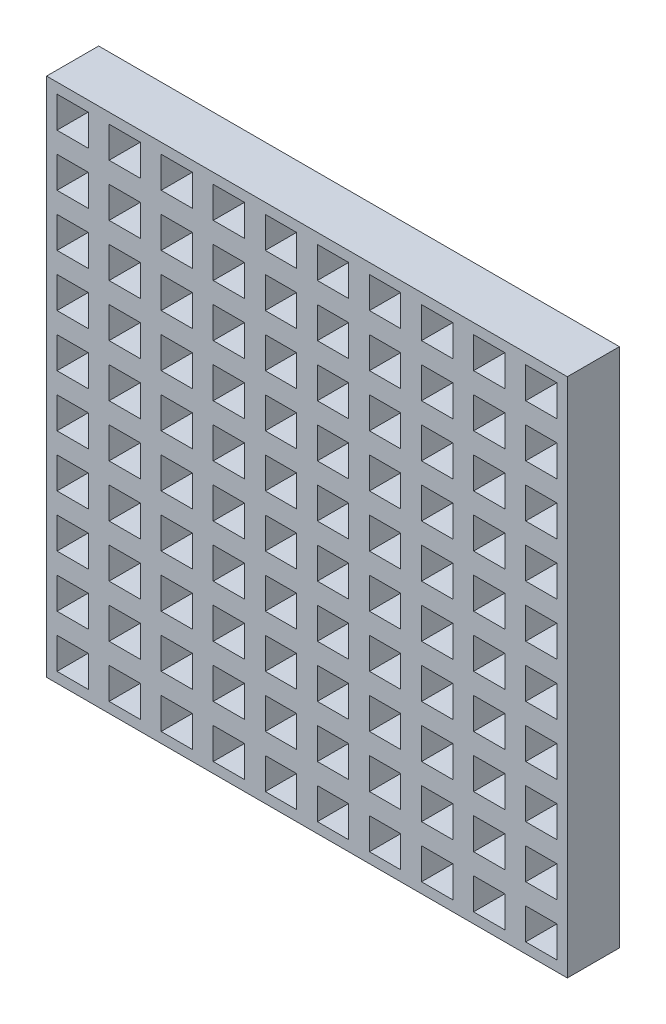
from build123d import *

# Parameters (mm, degrees)
SKETCH1_W           = 25.4
SKETCH1_H           = 25.4
BOSS_EXTRUDE1_DEPTH = 2.54
SKETCH2_W           = 1.524
SKETCH2_H           = 1.524
CUT_EXTRUDE1_DEPTH  = 2.54
LPATTERN1_COUNT     = 9
LPATTERN1_PITCH     = 2.54


with BuildPart() as part:
    # Sketch1 → Boss-Extrude1 (new body)
    with BuildSketch(Plane.XY):
        Rectangle(SKETCH1_W, SKETCH1_H)
    extrude(amount=BOSS_EXTRUDE1_DEPTH)

    # Sketch2 → Cut-Extrude1 (cut)
    with BuildSketch(Plane.XY.offset(2.54)):
        with Locations((-11.43, 8.89)):
            Rectangle(SKETCH2_W, SKETCH2_H)
        with Locations((-11.43, 3.81)):
            Rectangle(SKETCH2_W, SKETCH2_H)
        with Locations((-11.43, -1.27)):
            Rectangle(SKETCH2_W, SKETCH2_H)
        with Locations((-11.43, -3.81)):
            Rectangle(SKETCH2_W, SKETCH2_H)
        with Locations((-11.43, -6.35)):
            Rectangle(SKETCH2_W, SKETCH2_H)
        with Locations((-11.43, -8.89)):
            Rectangle(SKETCH2_W, SKETCH2_H)
        with Locations((-11.43, -11.43)):
            Rectangle(SKETCH2_W, SKETCH2_H)
        with Locations((-8.89, -11.43)):
            Rectangle(SKETCH2_W, SKETCH2_H)
        with Locations((-8.89, -8.89)):
            Rectangle(SKETCH2_W, SKETCH2_H)
        with Locations((-8.89, -6.35)):
            Rectangle(SKETCH2_W, SKETCH2_H)
        with Locations((-8.89, -3.81)):
            Rectangle(SKETCH2_W, SKETCH2_H)
        with Locations((-8.89, -1.27)):
            Rectangle(SKETCH2_W, SKETCH2_H)
        with Locations((-8.89, 1.27)):
            Rectangle(SKETCH2_W, SKETCH2_H)
        with Locations((-8.89, 6.35)):
            Rectangle(SKETCH2_W, SKETCH2_H)
        with Locations((-8.89, 8.89)):
            Rectangle(SKETCH2_W, SKETCH2_H)
        with Locations((-8.89, 11.43)):
            Rectangle(SKETCH2_W, SKETCH2_H)
        with Locations((-11.43, 11.43)):
            Rectangle(SKETCH2_W, SKETCH2_H)
        with Locations((-11.43, 1.27)):
            Rectangle(SKETCH2_W, SKETCH2_H)
        with Locations((-8.89, 3.81)):
            Rectangle(SKETCH2_W, SKETCH2_H)
        with Locations((-11.43, 6.35)):
            Rectangle(SKETCH2_W, SKETCH2_H)
    cut_extrude1 = extrude(amount=-CUT_EXTRUDE1_DEPTH, mode=Mode.SUBTRACT)

    # LPattern1: Cut-Extrude1 ×9
    with Locations(*[(i * LPATTERN1_PITCH, 0, 0) for i in range(1, LPATTERN1_COUNT)]):
        add(cut_extrude1, mode=Mode.SUBTRACT)


solid = part.part
